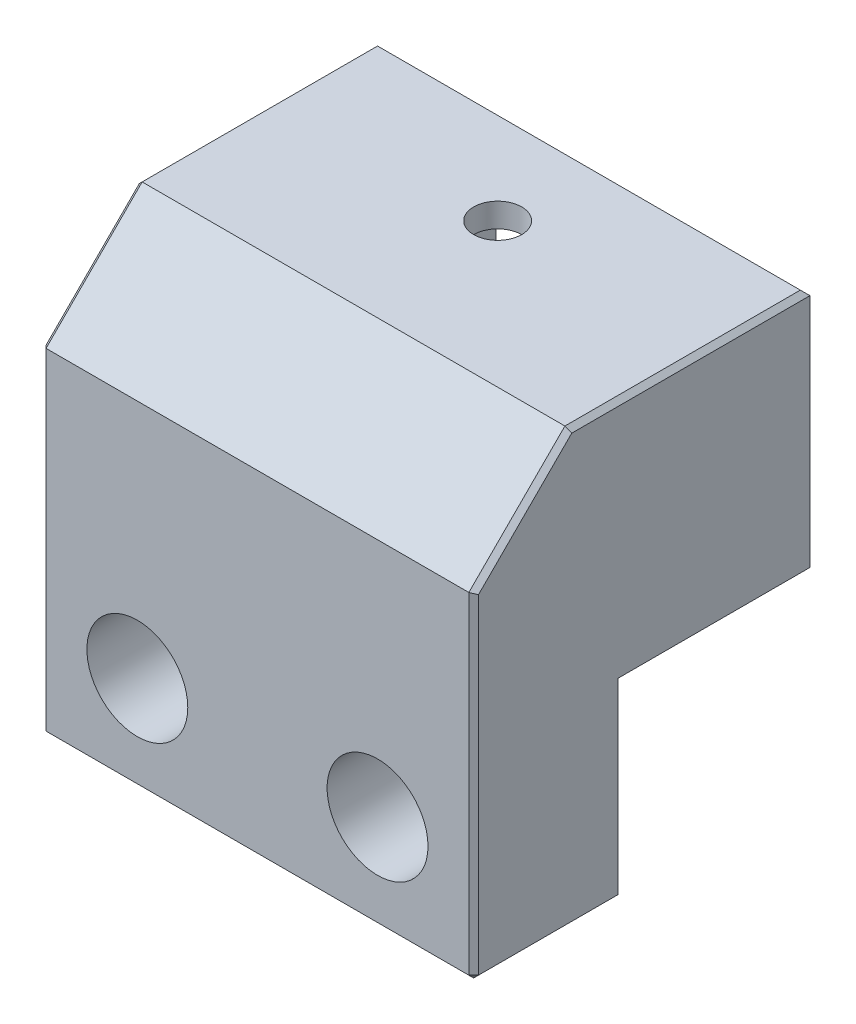
from build123d import *

# Parameters (mm, degrees)
SKETCH1_W                       = 45
SKETCH1_H                       = 20
SKETCH1_R                       = 2.5
BOSS_EXTRUDE1_DEPTH             = 25
SKETCH9_W                       = 45
SKETCH9_H                       = 45
BOSS_EXTRUDE4_DEPTH             = 15
CUT_EXTRUDE2_START              = -2.5
CUT_EXTRUDE2_DEPTH              = 19.5
CHAMFER1_SIZE                   = 10
CBORE_FOR_M5_SBHCS1_D           = 5.5
CBORE_FOR_M5_SBHCS1_CBORE_D     = 10.5
CBORE_FOR_M5_SBHCS1_CBORE_DEPTH = 9.75
CHAMFER2_SIZE                   = 0.5


with BuildPart() as part:
    # Sketch1 → Boss-Extrude1 (new body)
    with BuildSketch(Plane(origin=(0, 0, 0), x_dir=(1, 0, 0), z_dir=(0, 1, 0))):
        Rectangle(SKETCH1_W, SKETCH1_H)
        Circle(SKETCH1_R, mode=Mode.SUBTRACT)
    extrude(amount=BOSS_EXTRUDE1_DEPTH)

    # Sketch9 → Boss-Extrude4 (add)
    with BuildSketch(Plane.XY.offset(10)):
        with Locations((0, 2.5)):
            Rectangle(SKETCH9_W, SKETCH9_H)
    extrude(amount=BOSS_EXTRUDE4_DEPTH)

    # Sketch10 → Cut-Extrude2 (cut)
    with BuildSketch(Plane(origin=(0, 25, 0), x_dir=(1, 0, 0), z_dir=(0, 1, 0)).offset(CUT_EXTRUDE2_START)):
        with BuildLine():
            Line((10.16, 0), (10.16, 10))
            Line((10.16, 10), (-10.16, 10))
            Line((-10.16, 10), (-10.16, 0))
            ThreePointArc((-10.16, 0), (0, -10.16), (10.16, 0))
        make_face()
    extrude(amount=-CUT_EXTRUDE2_DEPTH, mode=Mode.SUBTRACT)

    # Chamfer1
    chamfer1_edges = [part.edges().sort_by_distance(p)[0] for p in [
        (0, 25, 25),
    ]]
    chamfer(chamfer1_edges, length=CHAMFER1_SIZE)

    # CBORE for M5 SBHCS1 (through all)
    with Locations(Plane.XY.offset(25)):
        with Locations((-12.5, -10), (12.5, -10)):
            CounterBoreHole(CBORE_FOR_M5_SBHCS1_D / 2, CBORE_FOR_M5_SBHCS1_CBORE_D / 2, CBORE_FOR_M5_SBHCS1_CBORE_DEPTH)

    # Chamfer2
    chamfer2_edges = [part.edges().sort_by_distance(p)[0] for p in [
        (-22.5, 25, 2.5),
        (-22.5, -20, 17.5),
        (22.5, -20, 17.5),
        (0, -20, 25),
        (22.5, -2.5, 25),
        (-22.5, -2.5, 25),
        (-22.5, 20, 20),
        (22.5, 25, 2.5),
        (22.5, 20, 20),
        (0, 25, -10),
    ]]
    chamfer(chamfer2_edges, length=CHAMFER2_SIZE)


solid = part.part
